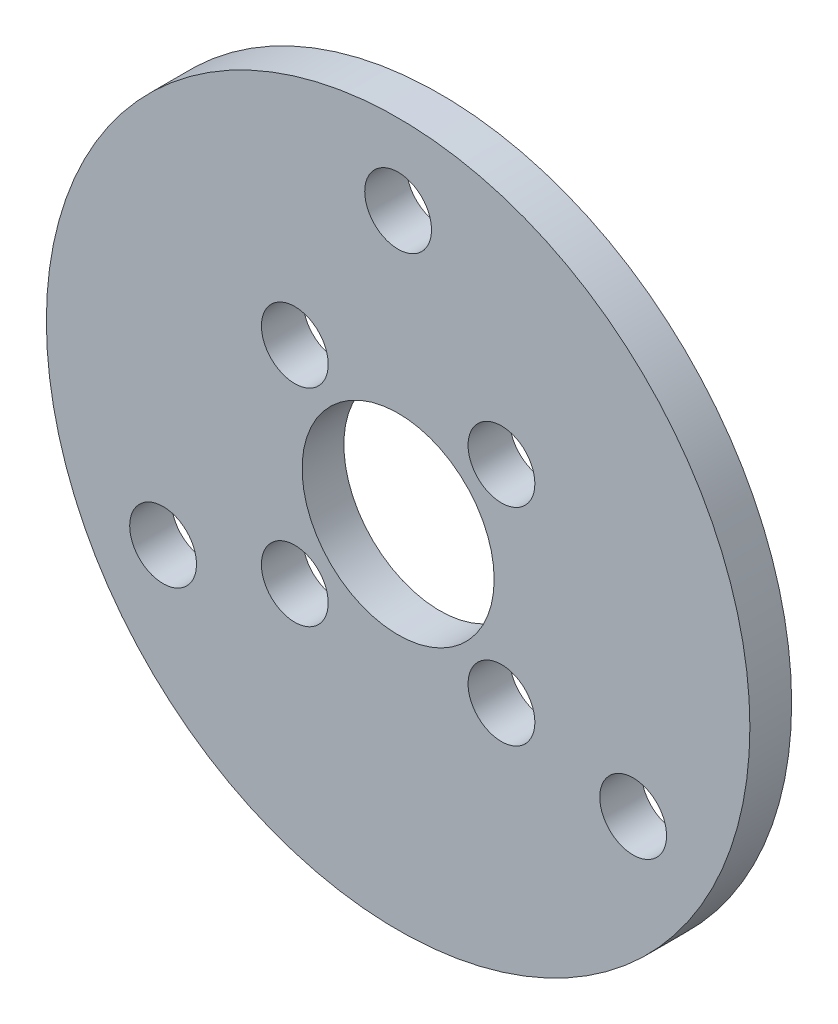
from build123d import *

# Parameters (mm, degrees)
SKETCH_1_R          = 16.85
SKETCH_1_R_2        = 1.6
SKETCH_1_R_3        = 4.6
EXTRUDE_1_DEPTH     = 2
SKETCH_2_R          = 1.6
CUT_EXTRUDE_1_DEPTH = 3


with BuildPart() as part:
    # 草图1 → 凸台-拉伸1 (new body)
    with BuildSketch(Plane.XY):
        Circle(SKETCH_1_R)
        with Locations((-4.949747468, 4.949747468)):
            Circle(SKETCH_1_R_2, mode=Mode.SUBTRACT)
        with Locations((-4.949747468, -4.949747468)):
            Circle(SKETCH_1_R_2, mode=Mode.SUBTRACT)
        with Locations((4.949747468, -4.949747468)):
            Circle(SKETCH_1_R_2, mode=Mode.SUBTRACT)
        with Locations((4.949747468, 4.949747468)):
            Circle(SKETCH_1_R_2, mode=Mode.SUBTRACT)
        Circle(SKETCH_1_R_3, mode=Mode.SUBTRACT)
    extrude(amount=EXTRUDE_1_DEPTH)

    # 草图2 → 切除-拉伸1 (cut, through all)
    with BuildSketch(Plane(origin=(0, 0, 0), x_dir=(-1, 0, 0), z_dir=(0, 0, -1))):
        with BuildLine():
            ThreePointArc((0, 14.6), (-1.6, 13), (0, 11.4))
            Line((0, 11.4), (0, 14.6))
        make_face()
        with BuildLine():
            Line((0, 14.6), (0, 11.4))
            ThreePointArc((0, 11.4), (1.13137085, 11.86862915), (1.6, 13))
            ThreePointArc((1.6, 13), (1.13137085, 14.13137085), (0, 14.6))
        make_face()
        with Locations((-11.258330249, -6.5)):
            Circle(SKETCH_2_R)
        with Locations((11.258330249, -6.5)):
            Circle(SKETCH_2_R)
    extrude(amount=-CUT_EXTRUDE_1_DEPTH, mode=Mode.SUBTRACT)


solid = part.part
